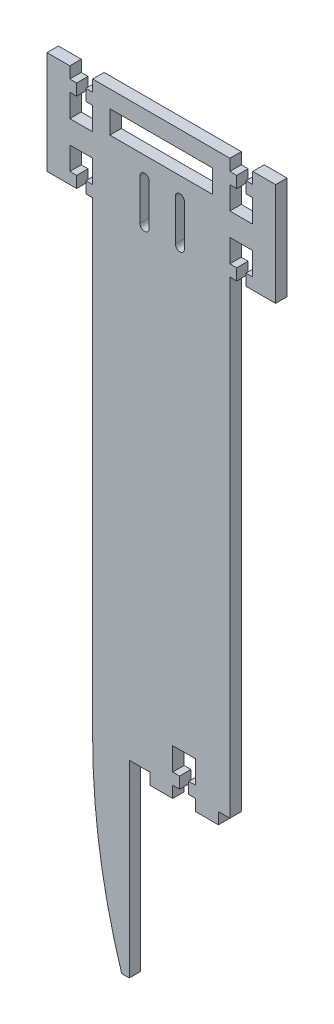
from build123d import *

# Parameters (mm, degrees)
BOSS_EXTRUDE1_DEPTH = 5
CUT_EXTRUDE3_DEPTH  = 5
SKETCH5_W           = 45
SKETCH5_H           = 10
CUT_EXTRUDE4_DEPTH  = 10
SKETCH6_W           = 10
SKETCH6_H           = 5
CUT_EXTRUDE5_DEPTH  = 5
SKETCH7_W           = 60
SKETCH7_H           = 5
BOSS_EXTRUDE2_DEPTH = 200
SKETCH8_W           = 10
SKETCH8_H           = 5
BOSS_EXTRUDE3_DEPTH = 5
SKETCH9_W           = 4
SKETCH9_H           = 5
CUT_EXTRUDE6_DEPTH  = 5
BOSS_EXTRUDE4_DEPTH = 5


with BuildPart() as part:
    # Sketch1 → Boss-Extrude1 (new body)
    with BuildSketch(Plane.XY):
        Polygon((0, -5), (10, -5), (10, 0), (13, 0), (13, 5), (10, 5), (10, 15), (20, 15), (20, 5), (17, 5), (17, 0), (20, 0), (20, -5), (80, -5), (80, 0), (83, 0), (83, 5), (80, 5), (80, 15), (90, 15), (90, 5), (87, 5), (87, 0), (90, 0), (90, -5), (100, -5), (100, 45), (90, 45), (90, 40), (87, 40), (87, 35), (90, 35), (90, 25), (80, 25), (80, 35), (83, 35), (83, 40), (80, 40), (80, 45), (20, 45), (20, 40), (17, 40), (17, 35), (20, 35), (20, 25), (10, 25), (10, 35), (13, 35), (13, 40), (10, 40), (10, 45), (0, 45), align=None)
    extrude(amount=-BOSS_EXTRUDE1_DEPTH)

    # Sketch4 → Cut-Extrude3 (cut)
    with BuildSketch(Plane(origin=(0, 0, -5), x_dir=(-1, 0, 0), z_dir=(0, 0, -1))):
        with BuildLine():
            Line((-60.15, 0.639479816), (-60.15, 18.639479816))
            ThreePointArc((-60.15, 18.639479816), (-58.15, 20.639479816), (-56.15, 18.639479816))
            Line((-56.15, 18.639479816), (-56.15, 0.639479816))
            ThreePointArc((-56.15, 0.639479816), (-58.15, -1.360520184), (-60.15, 0.639479816))
        make_face()
        with BuildLine():
            Line((-44.65, 0.639479816), (-44.65, 18.639479816))
            ThreePointArc((-44.65, 18.639479816), (-42.65, 20.639479816), (-40.65, 18.639479816))
            Line((-40.65, 18.639479816), (-40.65, 0.639479816))
            ThreePointArc((-40.65, 0.639479816), (-42.65, -1.360520184), (-44.65, 0.639479816))
        make_face()
    extrude(amount=-CUT_EXTRUDE3_DEPTH, mode=Mode.SUBTRACT)

    # Sketch5 → Cut-Extrude4 (cut)
    with BuildSketch(Plane(origin=(0, 0, -5), x_dir=(-1, 0, 0), z_dir=(0, 0, -1))):
        with Locations((-50, 32.5)):
            Rectangle(SKETCH5_W, SKETCH5_H)
    extrude(amount=-CUT_EXTRUDE4_DEPTH, mode=Mode.SUBTRACT)

    # Sketch6 → Cut-Extrude5 (cut)
    with BuildSketch(Plane.XY):
        with Locations((5, -2.5)):
            Rectangle(SKETCH6_W, SKETCH6_H)
        with Locations((95, -2.5)):
            Rectangle(SKETCH6_W, SKETCH6_H)
    extrude(amount=-CUT_EXTRUDE5_DEPTH, mode=Mode.SUBTRACT)

    # Sketch7 → Boss-Extrude2 (add)
    with BuildSketch(Plane.XZ.offset(5)):
        with Locations((50, -2.5)):
            Rectangle(SKETCH7_W, SKETCH7_H)
    extrude(amount=BOSS_EXTRUDE2_DEPTH)

    # Sketch8 → Boss-Extrude3 (add)
    with BuildSketch(Plane.XY):
        with Locations((50, -207.5)):
            Rectangle(SKETCH8_W, SKETCH8_H)
        with Locations((70, -207.5)):
            Rectangle(SKETCH8_W, SKETCH8_H)
    extrude(amount=-BOSS_EXTRUDE3_DEPTH)

    # Sketch9 → Cut-Extrude6 (cut)
    with BuildSketch(Plane.XY):
        Polygon((55, -200), (58, -200), (62, -200), (65, -200), (65, -190), (55, -190), align=None)
        with Locations((60, -202.5)):
            Rectangle(SKETCH9_W, SKETCH9_H)
    extrude(amount=-CUT_EXTRUDE6_DEPTH, mode=Mode.SUBTRACT)

    # Sketch10 → Boss-Extrude4 (add)
    with BuildSketch(Plane(origin=(0, 0, -5), x_dir=(-1, 0, 0), z_dir=(0, 0, -1))):
        with BuildLine():
            Line((-36, -287.5), (-32.66671961, -287.5))
            ThreePointArc((-32.66671961, -287.5), (-23.1851254, -246.733367303), (-20, -205))
            Line((-20, -205), (-36, -205))
            Line((-36, -205), (-36, -287.5))
        make_face()
    extrude(amount=-BOSS_EXTRUDE4_DEPTH)


solid = part.part
